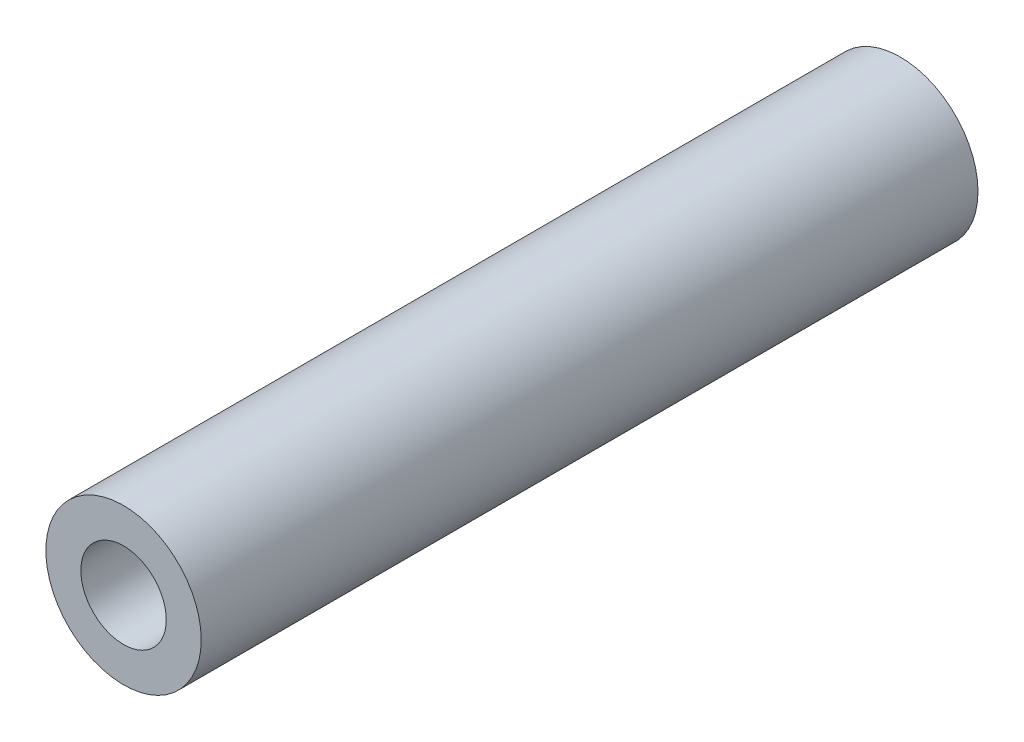
from build123d import *

# Parameters (mm, degrees)
SKETCH_1_R               = 3
EXTRUDE_1_DEPTH          = 15
M4X0_7_1_D               = 3.3
M4X0_7_1_DEPTH           = 8.5
M4X0_7_1_TIP             = 0.991420021
M4X0_7_1_ON_FACE_2_D     = 3.3
M4X0_7_1_ON_FACE_2_DEPTH = 8.5
M4X0_7_1_ON_FACE_2_TIP   = 0.991420021
M4X0_7_1_ON_FACE_3_D     = 3.3
M4X0_7_1_ON_FACE_3_DEPTH = 8.5
M4X0_7_1_ON_FACE_3_TIP   = 0.991420021


with BuildPart() as part:
    # ｽｹｯﾁ1 → ﾎﾞｽ - 押し出し1 (new body, symmetric)
    with BuildSketch(Plane.XY):
        Circle(SKETCH_1_R)
    extrude(amount=EXTRUDE_1_DEPTH, both=True)

    # M4x0.7 ねじ穴1
    with Locations(Plane.XY.offset(15)):
        with Locations((0, 0)):
            Hole(M4X0_7_1_D / 2, depth=M4X0_7_1_DEPTH)
            with Locations((0, 0, -(M4X0_7_1_DEPTH + M4X0_7_1_TIP / 2))):  # 118° drill point
                Cone(0, M4X0_7_1_D / 2, M4X0_7_1_TIP, mode=Mode.SUBTRACT)

    # M4x0.7 ねじ穴1 on face 2
    with Locations(Plane(origin=(0, 0, -15), x_dir=(-1, 0, 0), z_dir=(0, 0, -1))):
        with Locations((0, 0)):
            Hole(M4X0_7_1_ON_FACE_2_D / 2, depth=M4X0_7_1_ON_FACE_2_DEPTH)
            with Locations((0, 0, -(M4X0_7_1_ON_FACE_2_DEPTH + M4X0_7_1_ON_FACE_2_TIP / 2))):  # 118° drill point
                Cone(0, M4X0_7_1_ON_FACE_2_D / 2, M4X0_7_1_ON_FACE_2_TIP, mode=Mode.SUBTRACT)

    # M4x0.7 ねじ穴1 on face 3
    with Locations(Plane(origin=(8.523250275, 2.088443879, 0), x_dir=(1, 0, 0), z_dir=(0, 0, 1))):
        with Locations((0, 0)):
            Hole(M4X0_7_1_ON_FACE_3_D / 2, depth=M4X0_7_1_ON_FACE_3_DEPTH)
            with Locations((0, 0, -(M4X0_7_1_ON_FACE_3_DEPTH + M4X0_7_1_ON_FACE_3_TIP / 2))):  # 118° drill point
                Cone(0, M4X0_7_1_ON_FACE_3_D / 2, M4X0_7_1_ON_FACE_3_TIP, mode=Mode.SUBTRACT)


solid = part.part
